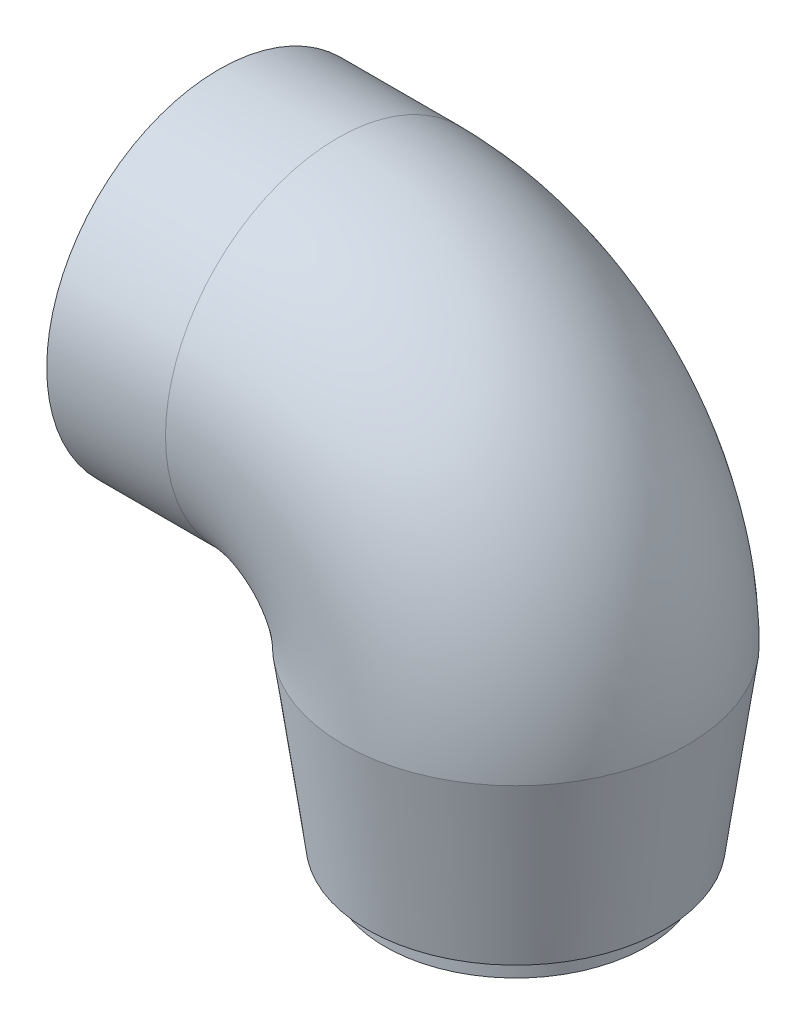
from build123d import *

# Parameters (mm, degrees)
SKETCH2_R          = 29
SKETCH2_R_2        = 25
SKETCH3_R          = 27
SKETCH3_R_2        = 25
CUT_EXTRUDE1_DEPTH = 7
SKETCH8_R          = 29
SKETCH8_R_2        = 22
CUT_EXTRUDE3_DEPTH = 4


with BuildPart() as part:
    # Sweep1: sweep along a path in Sketch1
    with BuildLine(Plane.XY) as sweep1_path:
        Line((-20, 30), (0, 30))
        ThreePointArc((0, 30), (21.213203436, 21.213203436), (30, 0))
        Line((30, 0), (30, -33))
    # Sketch2 → Sweep1 (sweep)
    with BuildSketch(Plane(origin=(0, -33, 0), x_dir=(1, 0, 0), z_dir=(0, 1, 0))):
        with Locations((30, 0)):
            Circle(SKETCH2_R)
        with Locations((30, 0)):
            Circle(SKETCH2_R_2, mode=Mode.SUBTRACT)
    sweep(path=sweep1_path.line)

    # Sketch3 → Cut-Extrude1 (cut)
    with BuildSketch(Plane.ZY.offset(20)):
        with Locations((0, 30)):
            Circle(SKETCH3_R)
        with Locations((0, 30)):
            Circle(SKETCH3_R_2, mode=Mode.SUBTRACT)
    extrude(amount=-CUT_EXTRUDE1_DEPTH, mode=Mode.SUBTRACT)

    # Sketch7 → Revolve2 (revolve)
    with BuildSketch(Plane(origin=(30, 0, 0), x_dir=(0, 0, -1), z_dir=(1, 0, 0))):
        Polygon((25, 0), (20, -33), (25, -33), align=None)
    revolve(axis=Axis((30, 0, 0), (0, -1, 0)))

    # Sketch8 → Cut-Extrude3 (cut)
    with BuildSketch(Plane.XZ.offset(33)):
        with Locations((30, 0)):
            Circle(SKETCH8_R)
        with Locations((30, 0)):
            Circle(SKETCH8_R_2, mode=Mode.SUBTRACT)
    extrude(amount=-CUT_EXTRUDE3_DEPTH, mode=Mode.SUBTRACT)

    # Sketch10 → Cut-Revolve2 (revolve, cut)
    with BuildSketch(Plane(origin=(30, 0, 0), x_dir=(0, 0, -1), z_dir=(1, 0, 0))):
        Polygon((29, 0), (25, -29), (29, -29), align=None)
    revolve(axis=Axis((30, 0, 0), (0, -1, 0)), mode=Mode.SUBTRACT)


solid = part.part
